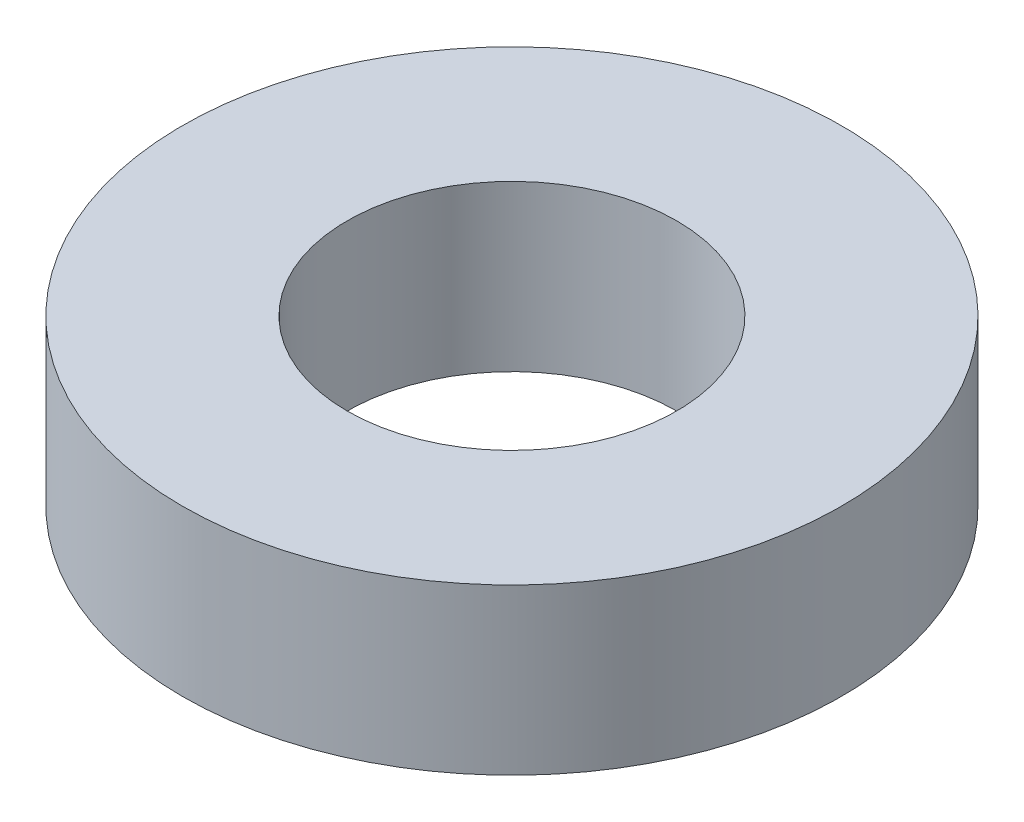
from build123d import *

# Parameters (mm, degrees)
SKETCH_1_R      = 8
SKETCH_1_R_2    = 4
EXTRUDE_1_DEPTH = 4


with BuildPart() as part:
    # 草图1 → 凸台-拉伸1 (new body)
    with BuildSketch(Plane(origin=(0, 0, 0), x_dir=(1, 0, 0), z_dir=(0, 1, 0))):
        Circle(SKETCH_1_R)
        Circle(SKETCH_1_R_2, mode=Mode.SUBTRACT)
    extrude(amount=EXTRUDE_1_DEPTH)


solid = part.part
